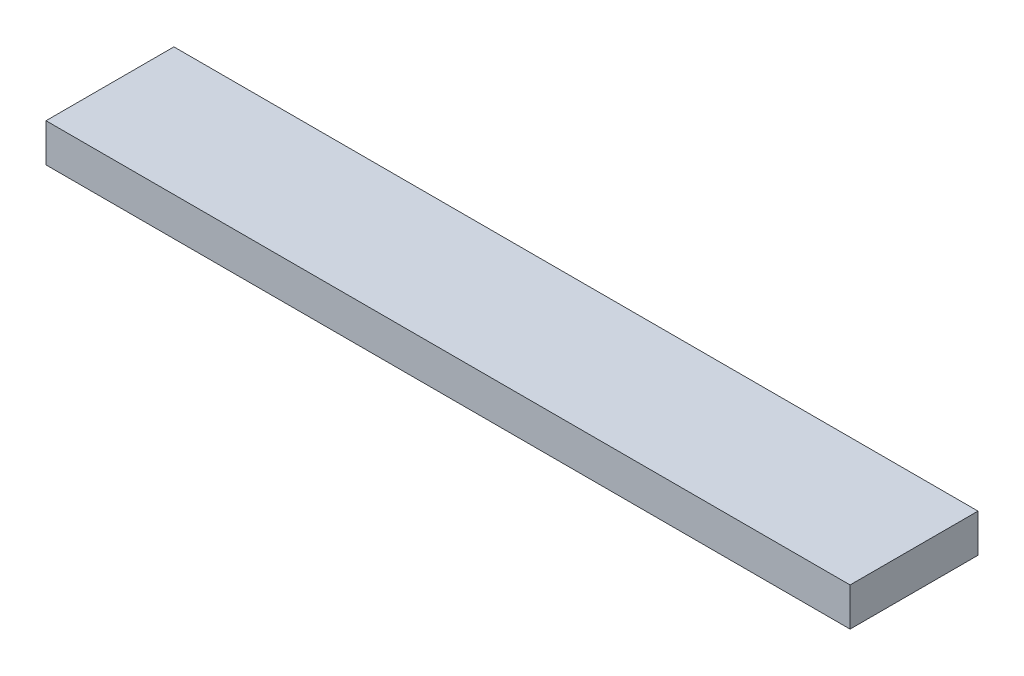
from build123d import *

# Parameters (mm, degrees)
ESQUISSE1_W        = 462
ESQUISSE1_H        = 22
BOSS_EXTRU_1_DEPTH = 73.5


with BuildPart() as part:
    # Esquisse1 → Boss.-Extru.1 (new body)
    with BuildSketch(Plane.XY):
        with Locations((30, 25)):
            Rectangle(ESQUISSE1_W, ESQUISSE1_H)
    extrude(amount=BOSS_EXTRU_1_DEPTH)


solid = part.part
